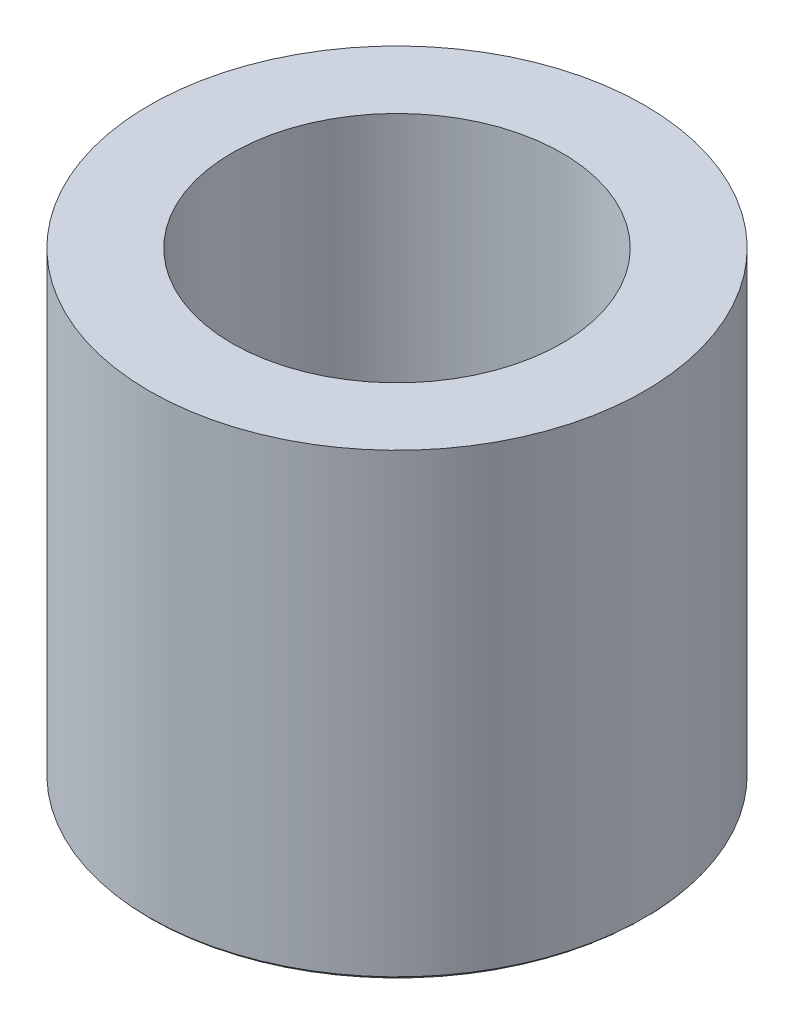
from build123d import *

# Parameters (mm, degrees)
SKETCH4_R           = 14.58
SKETCH4_R_2         = 9.58
BOSS_EXTRUDE1_DEPTH = 15
SKETCH5_R           = 14.58
SKETCH5_R_2         = 14.38
CUT_EXTRUDE1_DEPTH  = 31


with BuildPart() as part:
    # Sketch2 → Revolve1 (revolve)
    with BuildSketch(Plane.XY):
        with BuildLine():
            Line((9.58, 0), (14.58, 0))
            Line((14.58, 0), (14.58, -10.882649731))
            ThreePointArc((14.58, -10.882649731), (14.446025404, -11.382649731), (14.08, -11.748675135))
            Line((14.08, -11.748675135), (11.08, -13.480725942))
            ThreePointArc((11.08, -13.480725942), (10.08, -13.480725942), (9.58, -12.614700538))
            Line((9.58, -12.614700538), (9.58, 0))
        make_face()
    revolve(axis=Axis((0, 0, 0), (0, -1, 0)))

    # Sketch4 → Boss-Extrude1 (add)
    with BuildSketch(Plane(origin=(0, 0, 0), x_dir=(1, 0, 0), z_dir=(0, 1, 0))):
        Circle(SKETCH4_R)
        Circle(SKETCH4_R_2, mode=Mode.SUBTRACT)
    extrude(amount=BOSS_EXTRUDE1_DEPTH)

    # Sketch5 → Cut-Extrude1 (cut)
    with BuildSketch(Plane(origin=(0, 15, 0), x_dir=(1, 0, 0), z_dir=(0, 1, 0))):
        Circle(SKETCH5_R)
        Circle(SKETCH5_R_2, mode=Mode.SUBTRACT)
    extrude(amount=-CUT_EXTRUDE1_DEPTH, mode=Mode.SUBTRACT)


solid = part.part
